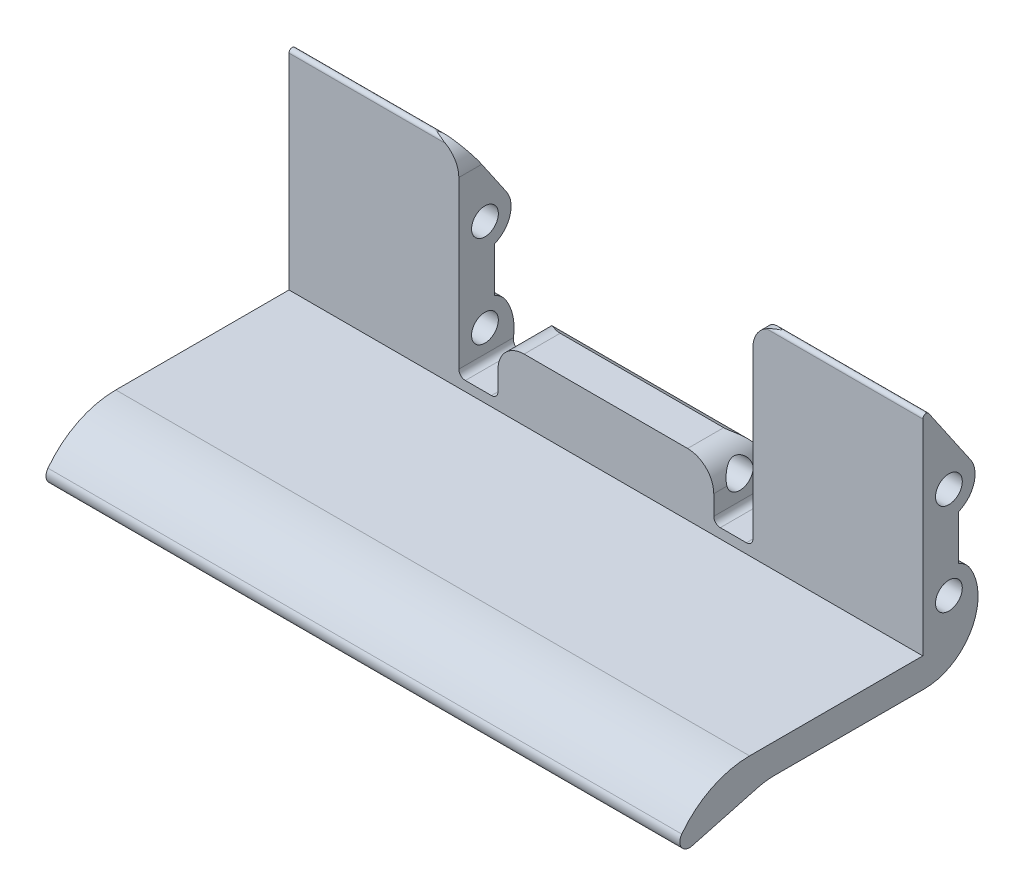
from build123d import *

# Parameters (mm, degrees)
SKETCH2_R           = 2.05
BOSS_EXTRUDE1_DEPTH = 97.028
CUT_EXTRUDE2_DEPTH  = 19.465030121


with BuildPart() as part:
    # Sketch2 → Boss-Extrude1 (new body)
    with BuildSketch(Plane(origin=(0, 0, 0), x_dir=(0, 0, -1), z_dir=(1, 0, 0))):
        with BuildLine():
            Line((-26.512665251, 4.5), (-3, 4.5))
            Line((-3, 4.5), (0, 4.5))
            Line((0, 4.5), (0, 7.5))
            Line((0, 7.5), (0, 35.905))
            ThreePointArc((0, 35.905), (0.352126006, 36.382632999), (0.912533128, 36.187517996))
            Line((0.912533128, 36.187517996), (7.300265025, 26.86014397))
            ThreePointArc((7.300265025, 26.86014397), (7.829571496, 23.444845397), (5.5, 20.891900756))
            Line((5.5, 20.891900756), (5.5, 14.006277796))
            ThreePointArc((5.5, 14.006277796), (6.490325157, 13.388297873), (7.247328797, 12.499709897))
            ThreePointArc((7.247328797, 12.499709897), (7.423857579, 4.201101474), (0.265030121, 0))
            Line((0.265030121, 0), (-22.684455065, 0))
            ThreePointArc((-22.684455065, 0), (-23.989716987, -0.085551386), (-25.272645516, -0.340741737))
            Line((-25.272645516, -0.340741737), (-35.31052949, -3.030384642))
            ThreePointArc((-35.31052949, -3.030384642), (-36.942206253, -2.420445594), (-36.896944076, -0.679082324))
            ThreePointArc((-36.896944076, -0.679082324), (-32.314736873, 3.133398682), (-26.512665251, 4.5))
        make_face()
        with Locations((4, 24.6)):
            Circle(SKETCH2_R, mode=Mode.SUBTRACT)
        with Locations((4, 10.5)):
            Circle(SKETCH2_R, mode=Mode.SUBTRACT)
    extrude(amount=BOSS_EXTRUDE1_DEPTH)

    # Sketch4 → Cut-Extrude2 (cut, through all)
    with BuildSketch(Plane.XY.offset(10)):
        with BuildLine():
            Line((26, 7), (26, 32.405))
            ThreePointArc((26, 32.405), (24.828427125, 35.233427125), (22, 36.405))
            Line((22, 36.405), (75.028, 36.405))
            ThreePointArc((75.028, 36.405), (72.199572875, 35.233427125), (71.028, 32.405))
            Line((71.028, 32.405), (71.028, 7))
            ThreePointArc((71.028, 7), (70.735106781, 6.292893219), (70.028, 6))
            Line((70.028, 6), (66.028, 6))
            ThreePointArc((66.028, 6), (65.320893219, 6.292893219), (65.028, 7))
            Line((65.028, 7), (65.028, 10))
            ThreePointArc((65.028, 10), (63.856427125, 12.828427125), (61.028, 14))
            Line((61.028, 14), (36, 14))
            ThreePointArc((36, 14), (33.171572875, 12.828427125), (32, 10))
            Line((32, 10), (32, 7))
            ThreePointArc((32, 7), (31.707106781, 6.292893219), (31, 6))
            Line((31, 6), (27, 6))
            ThreePointArc((27, 6), (26.292893219, 6.292893219), (26, 7))
        make_face()
    extrude(amount=-CUT_EXTRUDE2_DEPTH, mode=Mode.SUBTRACT)


solid = part.part
